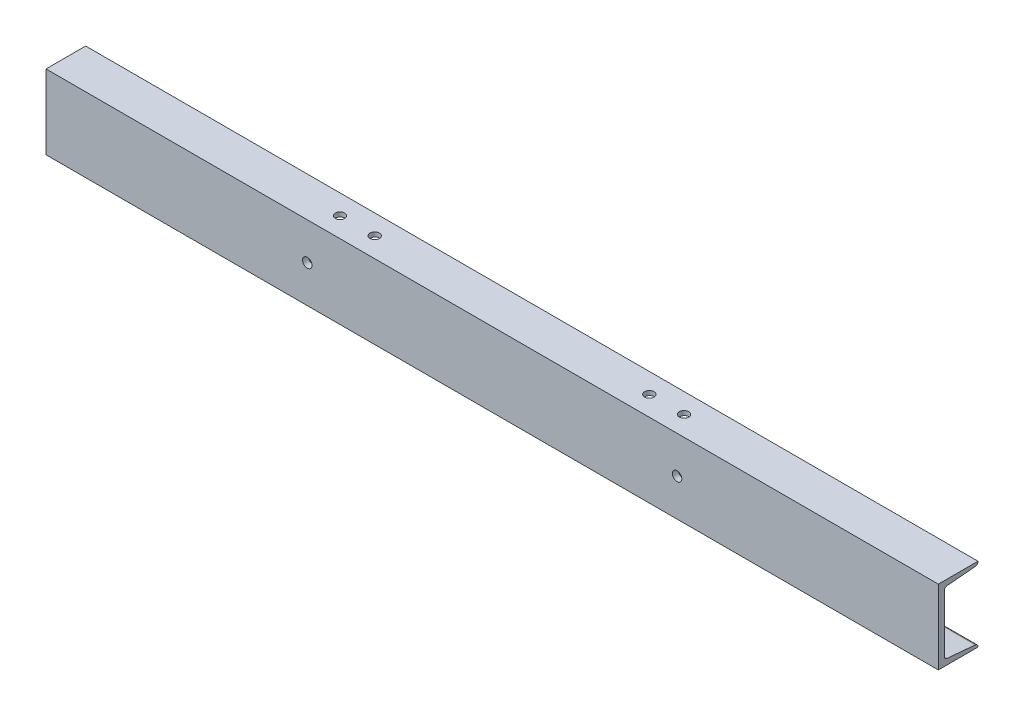
from build123d import *

# Parameters (mm, degrees)
STRUCTURAL_MEMBER1_DEPTH = 900
SKETCH12_R               = 4.7625
CUT_EXTRUDE1_DEPTH       = 454.327971782
CUT_EXTRUDE2_DEPTH       = 40
SKETCH16_R               = 4.7625
CUT_EXTRUDE3_DEPTH       = 454.327971881
SKETCH17_R               = 4.7625
CUT_EXTRUDE4_DEPTH       = 454.327971881


with BuildPart() as part:
    # Sketch19 → Structural Member1 (new body)
    with BuildSketch(Plane(origin=(-450, 0, 0), x_dir=(0, 0, 1), z_dir=(1, 0, 0))):
        with BuildLine():
            Line((0, 37.5), (0, -37.5))
            Line((0, -37.5), (-40, -37.5))
            Line((-40, -37.5), (-40, -37.246949676))
            ThreePointArc((-40, -37.246949676), (-39.212582687, -35.220998578), (-37.263681431, -34.258560126))
            Line((-37.263681431, -34.258560126), (-8.736318569, -31.741439874))
            ThreePointArc((-8.736318569, -31.741439874), (-6.787417313, -30.779001422), (-6, -28.753050324))
            Line((-6, -28.753050324), (-6, 28.753050324))
            ThreePointArc((-6, 28.753050324), (-6.787417313, 30.779001422), (-8.736318569, 31.741439874))
            Line((-8.736318569, 31.741439874), (-37.263681431, 34.258560126))
            ThreePointArc((-37.263681431, 34.258560126), (-39.212582687, 35.220998578), (-40, 37.246949676))
            Line((-40, 37.246949676), (-40, 37.5))
            Line((-40, 37.5), (0, 37.5))
        make_face()
    extrude(amount=STRUCTURAL_MEMBER1_DEPTH)

    # Sketch12 → Cut-Extrude1 (cut, through all)
    with BuildSketch(Plane(origin=(0, 0, 0), x_dir=(1, 0, 0), z_dir=(0, 1, 0))):
        with Locations(Location((-425, 20, 0), (0, 0, 270))):
            Circle(SKETCH12_R)
        with Locations(Location((425, 20, 0), (0, 0, 270))):
            Circle(SKETCH12_R)
    extrude(amount=-CUT_EXTRUDE1_DEPTH, mode=Mode.SUBTRACT)

    # Sketch15 → Cut-Extrude2 (cut)
    with BuildSketch(Plane(origin=(0, 0, -6), x_dir=(-1, 0, 0), z_dir=(0, 0, -1))):
        with BuildLine():
            Line((-412.5, 22.5), (-437.5, 22.5))
            ThreePointArc((-437.5, 22.5), (-442.5, 27.5), (-437.5, 32.5))
            Line((-437.5, 32.5), (-412.5, 32.5))
            ThreePointArc((-412.5, 32.5), (-407.5, 27.5), (-412.5, 22.5))
        make_face()
        with BuildLine():
            Line((412.5, 22.5), (437.5, 22.5))
            ThreePointArc((437.5, 22.5), (442.5, 27.5), (437.5, 32.5))
            Line((437.5, 32.5), (412.5, 32.5))
            ThreePointArc((412.5, 32.5), (407.5, 27.5), (412.5, 22.5))
        make_face()
    extrude(amount=CUT_EXTRUDE2_DEPTH, mode=Mode.SUBTRACT)

    # Sketch16 → Cut-Extrude3 (cut, through all)
    with BuildSketch(Plane(origin=(0, 0, 0), x_dir=(1, 0, 0), z_dir=(0, 1, 0))):
        with Locations(Location((-173.5, 20, 0), (0, 0, 270))):
            Circle(SKETCH16_R)
        with Locations(Location((-138.5, 20, 0), (0, 0, 270))):
            Circle(SKETCH16_R)
        with Locations(Location((138.5, 20, 0), (0, 0, 90))):
            Circle(SKETCH16_R)
        with Locations(Location((173.5, 20, 0), (0, 0, 90))):
            Circle(SKETCH16_R)
    extrude(amount=CUT_EXTRUDE3_DEPTH, mode=Mode.SUBTRACT)

    # Sketch17 → Cut-Extrude4 (cut, through all)
    with BuildSketch(Plane.XY):
        with Locations((-186.5, 0)):
            Circle(SKETCH17_R)
        with Locations((186.5, 0)):
            Circle(SKETCH17_R)
    extrude(amount=-CUT_EXTRUDE4_DEPTH, mode=Mode.SUBTRACT)


solid = part.part
